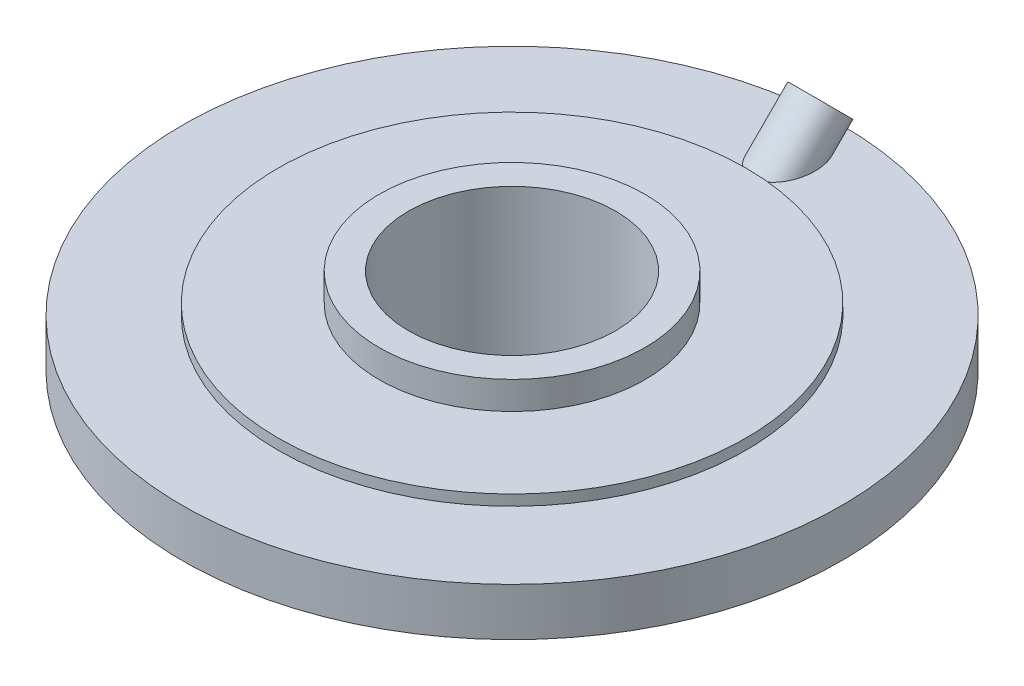
from build123d import *

# Parameters (mm, degrees)
SKETCH2_R           = 19.5
CUT_EXTRUDE1_DEPTH  = 90
BOSS_EXTRUDE1_REACH = 112.853
SKETCH5_R           = 5
SKETCH6_R           = 1.5
CUT_EXTRUDE3_DEPTH  = 28


with BuildPart() as part:
    # Sketch1 → Revolve2 (revolve)
    with BuildSketch(Plane.XY):
        Polygon((0, 0), (25, 0), (25, -5.236486486), (44, -5.236486486), (44, -7.236486486), (62, -7.236486486), (62, -16.236486486), (30.5, -16.236486486), (30.5, -19.236486486), (26, -19.236486486), (26, -38.006756757), (0, -38.006756757), align=None)
    revolve(axis=Axis((0, -38.006756757, 0), (0, 1, 0)))

    # Sketch2 → Cut-Extrude1 (cut)
    with BuildSketch(Plane(origin=(0, 0, 0), x_dir=(1, 0, 0), z_dir=(0, 1, 0))):
        Circle(SKETCH2_R)
    extrude(amount=-CUT_EXTRUDE1_DEPTH, mode=Mode.SUBTRACT)

    # Boss-Extrude1: up to this face of the body (flat: up to its plane)
    boss_extrude1_end = Plane(part.part.faces().sort_by_distance((-45.753624817, -7.236486486, 0))[0])
    # Sketch5 → Boss-Extrude1 (add, up to the picked face)
    with BuildSketch(Plane(origin=(0, -1.236486486, -58), x_dir=(-1, 0, 0), z_dir=(0, 0.707106781, -0.707106781)), mode=Mode.PRIVATE) as boss_extrude1_sk1:
        Circle(SKETCH5_R)
    boss_extrude1_tool1 = split(extrude(boss_extrude1_sk1.sketch, amount=-BOSS_EXTRUDE1_REACH, mode=Mode.PRIVATE), bisect_by=boss_extrude1_end, keep=Keep.BOTH, mode=Mode.PRIVATE)
    add(boss_extrude1_tool1.solids().sort_by_distance((0, -1.236486, -58))[0])

    # Sketch6 → Cut-Extrude3 (cut)
    with BuildSketch(Plane(origin=(0, 28.381756757, -28.381756757), x_dir=(1, 0, 0), z_dir=(0, 0.707106781, -0.707106781))):
        with Locations((0, 41.886521288)):
            Circle(SKETCH6_R)
    extrude(amount=-CUT_EXTRUDE3_DEPTH, mode=Mode.SUBTRACT)


solid = part.part
